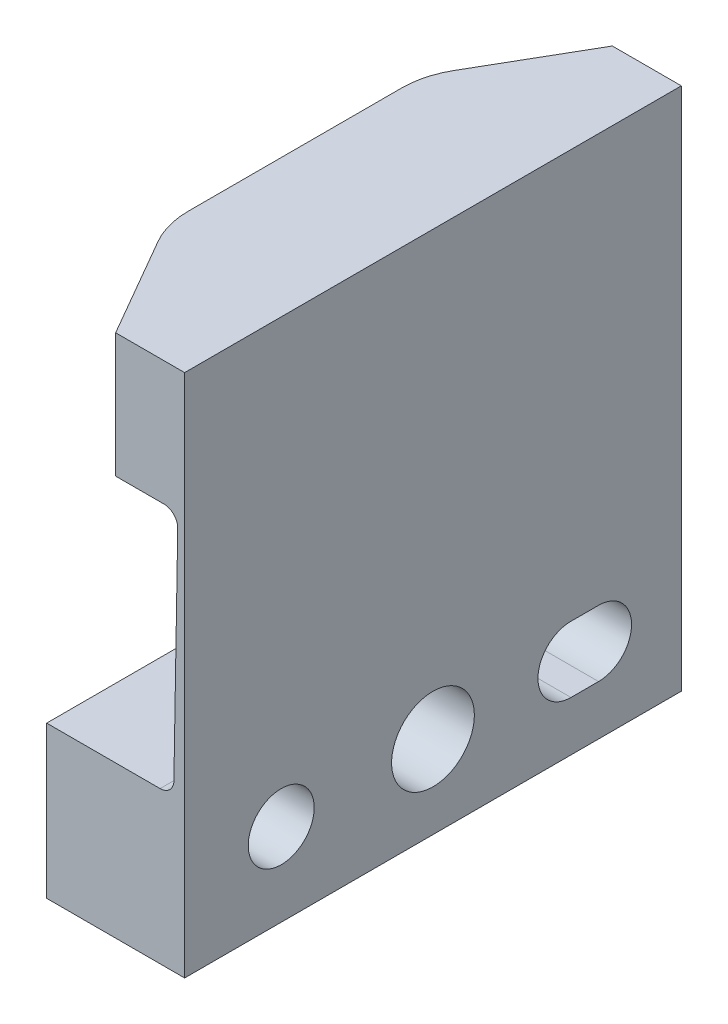
from build123d import *

# Parameters (mm, degrees)
BOSS_EXTRUDE1_DEPTH = 9
CHAMFER1_SIZE       = 2.5
CHAMFER1_SIZE2      = 4.330127019
FILLET1_R           = 3
SKETCH11_R          = 1.195625
SKETCH11_R_2        = 1.5
CUT_EXTRUDE1_DEPTH  = 6
CUT_EXTRUDE2_DEPTH  = 0.5


with BuildPart() as part:
    # Sketch4 → Boss-Extrude1 (new body)
    with BuildSketch(Plane.XY):
        with BuildLine():
            Line((0, 19.5), (0, 14.5))
            Line((0, 14.5), (4.250076152, 14.5))
            ThreePointArc((4.250076152, 14.5), (4.606701377, 14.350454632), (4.75, 13.991273797))
            Line((4.75, 13.991273797), (4.610359481, 5.991273797))
            ThreePointArc((4.610359481, 5.991273797), (4.460890265, 5.643374775), (4.110435633, 5.5))
            Line((4.110435633, 5.5), (0, 5.5))
            Line((0, 5.5), (0, 0))
            Line((0, 0), (5, 0))
            Line((5, 0), (5, 19.5))
            Line((5, 19.5), (0, 19.5))
        make_face()
    extrude(amount=BOSS_EXTRUDE1_DEPTH)

    # Chamfer1
    chamfer1_edges = [part.edges().sort_by_distance(p)[0] for p in [
        (0, 17, 9),
    ]]
    chamfer1_side = [part.faces().sort_by_distance(p)[0] for p in [
        (0.201308221, 17, 9),
    ]]
    chamfer(chamfer1_edges, length=CHAMFER1_SIZE, length2=CHAMFER1_SIZE2, reference=chamfer1_side[0])

    # Fillet1
    fillet1_edges = [part.edges().sort_by_distance(p)[0] for p in [
        (0, 17, 4.669872981),
    ]]
    fillet(fillet1_edges, radius=FILLET1_R)

    # Mirror1: part across plane


with BuildPart() as part_1:
    add(part.part)
    add(part.part.mirror(Plane(origin=(4.250076152, 14, 0), x_dir=(1, 0, 0), z_dir=(0, 0, -1))))

    # Sketch11 → Cut-Extrude1 (cut, through all)
    with BuildSketch(Plane(origin=(5, 0, 0), x_dir=(0, 0, -1), z_dir=(1, 0, 0))):
        with Locations((-5.5, 3)):
            Circle(SKETCH11_R)
        with Locations((0, 3)):
            Circle(SKETCH11_R_2)
        with BuildLine():
            Line((5, 4.195625), (6, 4.195625))
            ThreePointArc((6, 4.195625), (7.195625, 3), (6, 1.804375))
            Line((6, 1.804375), (5, 1.804375))
            ThreePointArc((5, 1.804375), (3.804375, 3), (5, 4.195625))
        make_face()
    extrude(amount=-CUT_EXTRUDE1_DEPTH, mode=Mode.SUBTRACT)

    # Sketch12 → Cut-Extrude2 (cut)
    with BuildSketch(Plane(origin=(0, 19.5, 0), x_dir=(1, 0, 0), z_dir=(0, 1, 0))):
        with BuildLine():
            Line((0, 3.866025404), (0, -3.866025404))
            ThreePointArc((0, -3.866025404), (0.102222521, -4.642482539), (0.401923789, -5.366025404))
            Line((0.401923789, -5.366025404), (2.5, -9))
            Line((2.5, -9), (5, -9))
            Line((5, -9), (5, 9))
            Line((5, 9), (2.5, 9))
            Line((2.5, 9), (0.401923789, 5.366025404))
            ThreePointArc((0.401923789, 5.366025404), (0.102222521, 4.642482539), (0, 3.866025404))
        make_face()
    extrude(amount=-CUT_EXTRUDE2_DEPTH, mode=Mode.SUBTRACT)


solid = part_1.part
